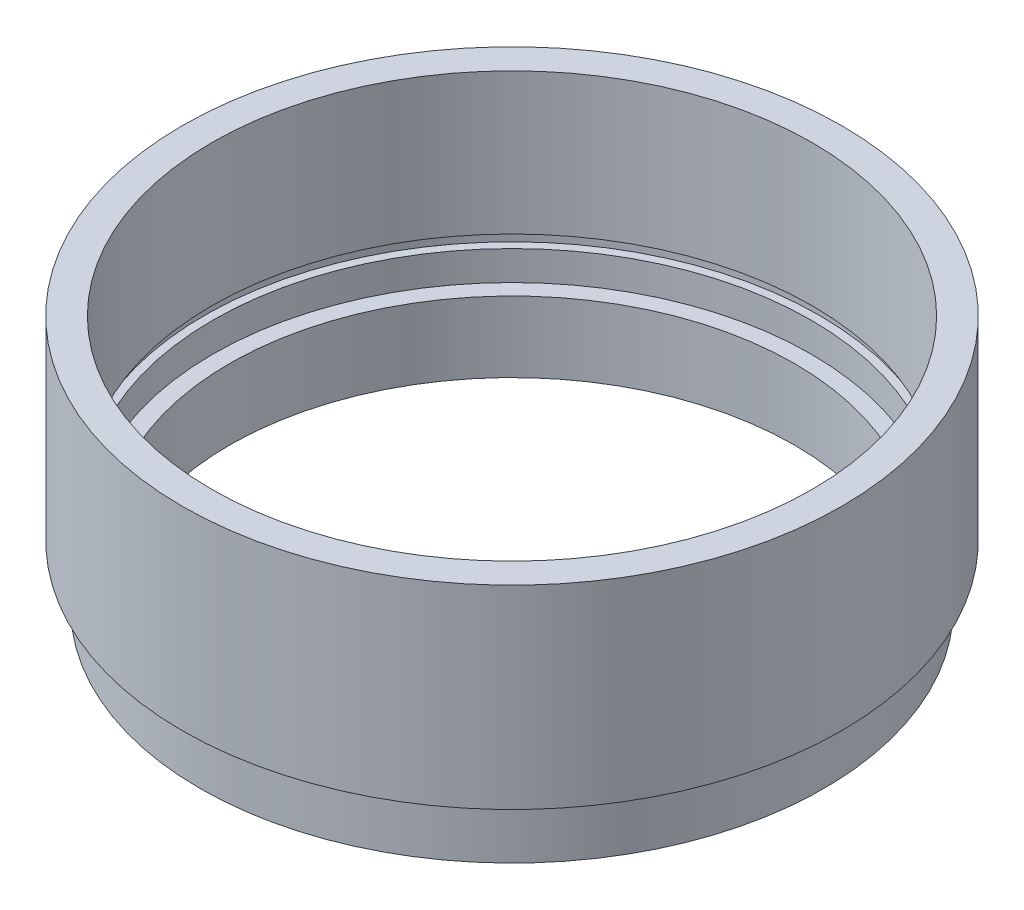
from build123d import *


with BuildPart() as part:
    # 草图1 → 旋转1 (revolve)
    with BuildSketch(Plane.XY, mode=Mode.PRIVATE) as revolve_1_sk:
        Polygon((24, 0), (26.5, 0), (26.5, 4), (25.5, 4), (25.5, 5), (28, 5), (28, 21.5), (25.5, 21.5), (25.5, 9.5), (26.1, 9.5), (26.1, 8.5), (25.4, 8.5), (25.4, 6), (24, 6), align=None)
    revolve(revolve_1_sk.sketch.rotate(Axis((0, 0, 0), (0, 1, 0)), 90), axis=Axis((0, 0, 0), (0, 1, 0)))  # turned: the seam where the file's is


solid = part.part
